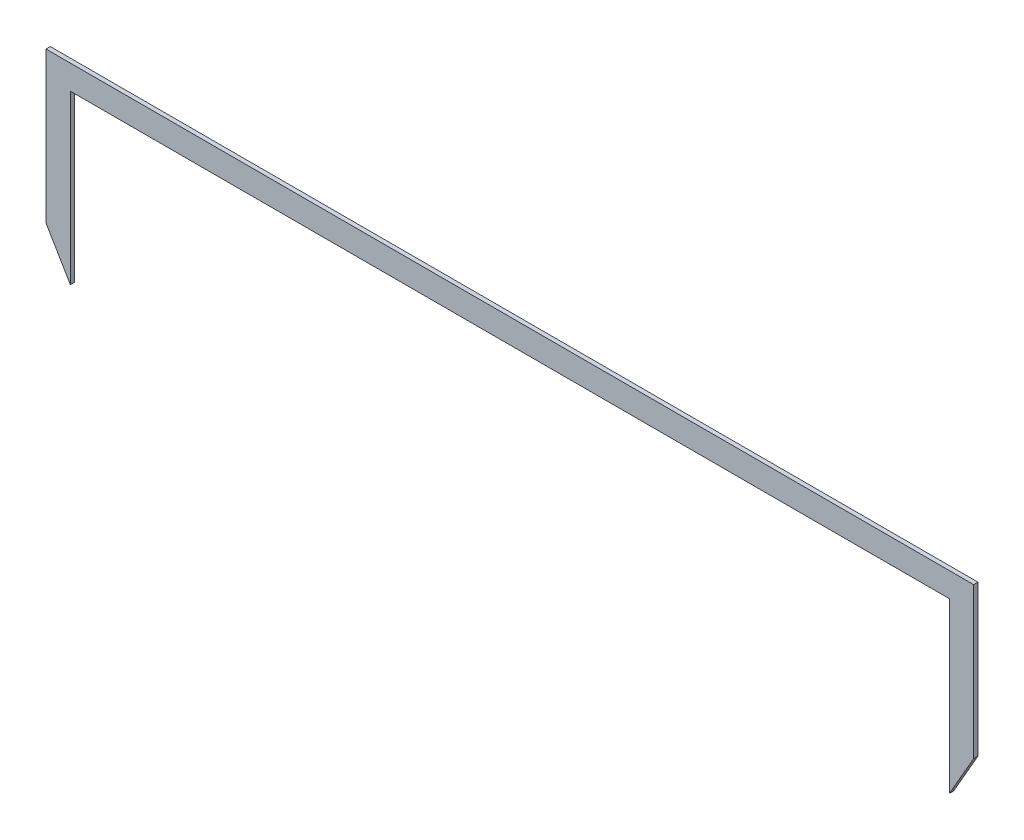
from build123d import *

# Parameters (mm, degrees)
BOSS_EXTRUDE1_DEPTH = 3


with BuildPart() as part:
    # Sketch2 → Boss-Extrude1 (new body)
    with BuildSketch(Plane.XY):
        Polygon((-861.468217561, 500.606896828), (-213.467780542, 500.606896828), (-213.467780542, 395.374747166), (-230.466465748, 365.786721753), (-230.466465748, 483.608211622), (-844.469532355, 483.608211622), (-844.469532355, 366.542670365), (-861.468217561, 395.374747166), align=None)
    extrude(amount=BOSS_EXTRUDE1_DEPTH)


solid = part.part
